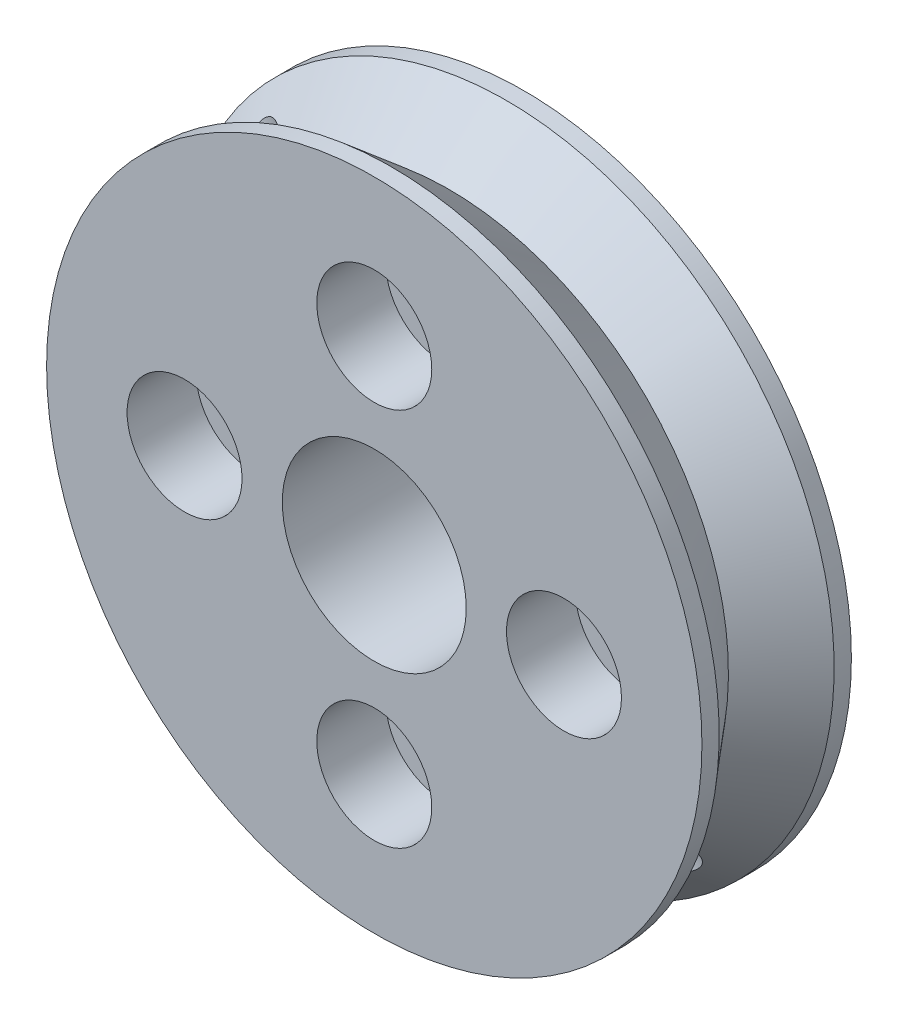
from build123d import *

# Parameters (mm, degrees)
ESQUISSE2_R                  = 14.25
BOSS_EXTRU_1_DEPTH           = 3.25
ESQUISSE3_R                  = 1.2
ENL_V_MAT_EXTRU_1_DEPTH      = 4.25
ESQUISSE10_R                 = 1.7
ENL_V_MAT_EXTRU_2_DEPTH      = 1
ENL_V_MAT_EXTRU_2_DEPTH_BACK = 7.5
ESQUISSE17_R                 = 4
ENL_V_MAT_EXTRU_8_DEPTH      = 7.5
ESQUISSE13_R                 = 1.4
ENL_V_MAT_EXTRU_4_DEPTH      = 35.402543264
ESQUISSE20_R                 = 2.5
ENL_V_MAT_EXTRU_9_DEPTH      = 3


with BuildPart() as part:
    # Esquisse2 → Boss.-Extru.1 (new body, symmetric)
    with BuildSketch(Plane.XY):
        Circle(ESQUISSE2_R)
    extrude(amount=BOSS_EXTRU_1_DEPTH, both=True)

    # Esquisse3 → Enlèv. mat.-Extru.1 (cut, through all)
    with BuildSketch(Plane.XY):
        with Locations((0, 8.25)):
            Circle(ESQUISSE3_R)
        with Locations((-8.25, 0)):
            Circle(ESQUISSE3_R)
        with Locations((0, -8.25)):
            Circle(ESQUISSE3_R)
        with Locations((8.25, 0)):
            Circle(ESQUISSE3_R)
    extrude(amount=ENL_V_MAT_EXTRU_1_DEPTH, mode=Mode.SUBTRACT)

    # Esquisse10 → Enlèv. mat.-Extru.2 (cut, two sides)
    with BuildSketch(Plane(origin=(0, 0, -3.25), x_dir=(-1, 0, 0), z_dir=(0, 0, -1))) as enl_v_mat_extru_2_sk:
        with Locations((-8.25, 0)):
            Circle(ESQUISSE10_R)
        with Locations((0, 8.25)):
            Circle(ESQUISSE10_R)
        with Locations((8.25, 0)):
            Circle(ESQUISSE10_R)
        with Locations((0, -8.25)):
            Circle(ESQUISSE10_R)
    extrude(amount=ENL_V_MAT_EXTRU_2_DEPTH, mode=Mode.SUBTRACT)
    extrude(enl_v_mat_extru_2_sk.sketch, amount=-ENL_V_MAT_EXTRU_2_DEPTH_BACK, mode=Mode.SUBTRACT)

    # Esquisse17 → Enlèv. mat.-Extru.8 (cut, through all)
    with BuildSketch(Plane.XY.offset(3.25)):
        Circle(ESQUISSE17_R)
    extrude(amount=-ENL_V_MAT_EXTRU_8_DEPTH, mode=Mode.SUBTRACT)

    # Esquisse13 → Enlèv. mat.-Extru.4 (cut, through all)
    with BuildSketch(Plane(origin=(10.076271632, -10.076271632, 0), x_dir=(-0.707106781, -0.707106781, 0), z_dir=(0.707106781, -0.707106781, 0))):
        Circle(ESQUISSE13_R)
    extrude(amount=-ENL_V_MAT_EXTRU_4_DEPTH, mode=Mode.SUBTRACT)

    # Esquisse18 → Enlèvement de matière-Révolution1 (revolve, cut)
    with BuildSketch(Plane(origin=(0, 0, 0), x_dir=(1, 0, 0), z_dir=(0, 1, 0))):
        Polygon((14.25, 2.5), (12.152250922, 0), (14.25, -2.5), align=None)
    revolve(axis=Axis((0, 0, -3.25), (0, 0, 1)), mode=Mode.SUBTRACT)

    # Esquisse20 → Enlèv. mat.-Extru.9 (cut)
    with BuildSketch(Plane.XY.offset(3.25)):
        with Locations((0, 8.25)):
            Circle(ESQUISSE20_R)
        with Locations((8.25, 0)):
            Circle(ESQUISSE20_R)
        with Locations((-8.25, 0)):
            Circle(ESQUISSE20_R)
        with Locations((0, -8.25)):
            Circle(ESQUISSE20_R)
    extrude(amount=-ENL_V_MAT_EXTRU_9_DEPTH, mode=Mode.SUBTRACT)


solid = part.part
